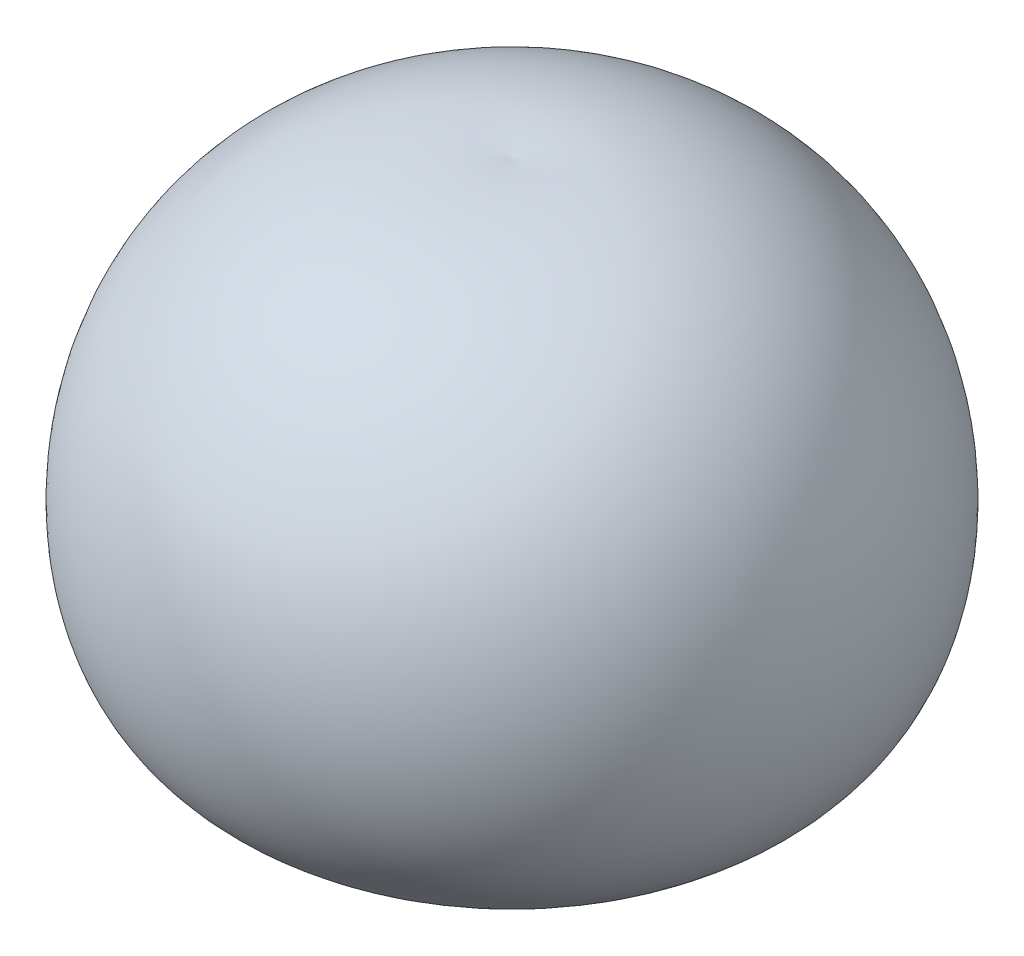
from build123d import *


with BuildPart() as part:
    # Croquis1 → Revolución1 (revolve)
    with BuildSketch(Plane.XY):
        with BuildLine():
            Line((0, 0), (0, 57))
            add(Edge.make_bspline(
                [(0, 0), (9.363727443, -1.029957566), (35.327955924, 2.430934502), (37.823828868, 44.073012437), (15.999574749, 58.833656121), (0, 57)],
                knots=[0, 0, 0, 0, 0.320082548, 0.582991776, 1, 1, 1, 1], degree=3))
        make_face()
    revolve(axis=Axis((0, 0, 0), (0, 1, 0)))


solid = part.part
